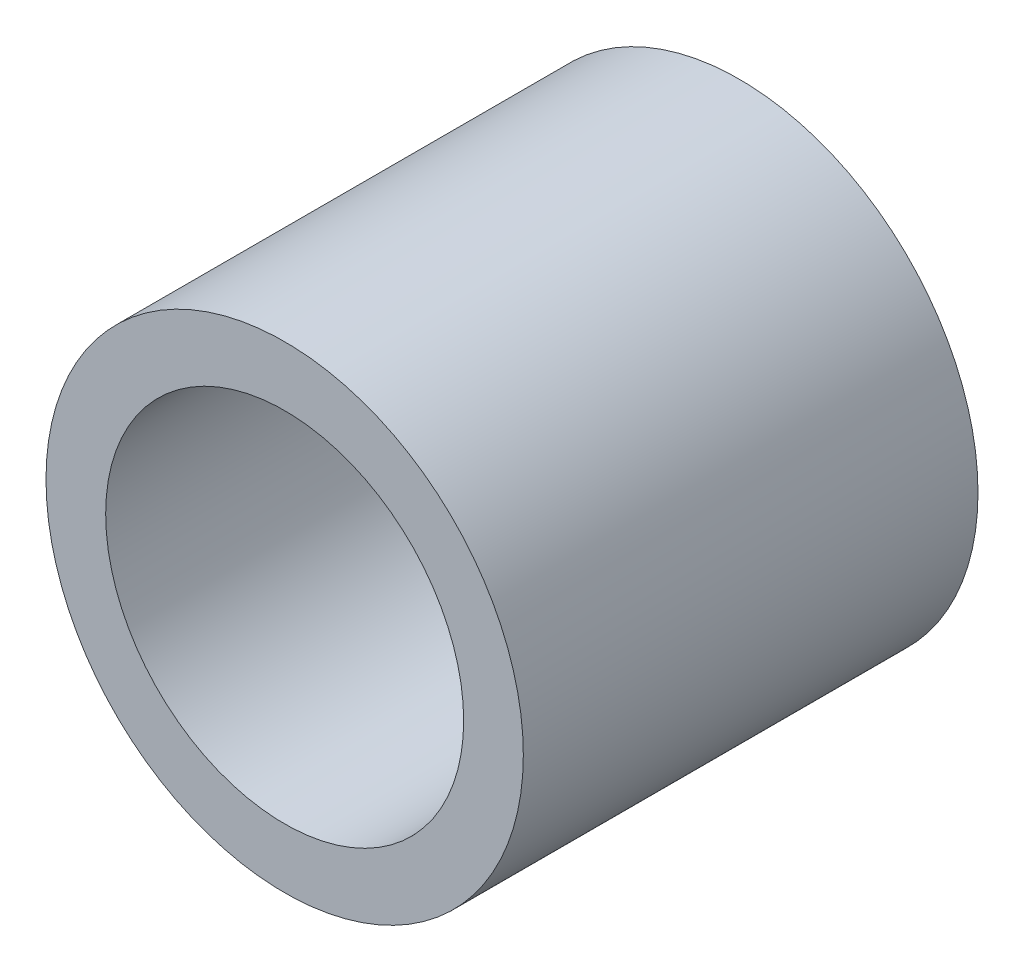
from build123d import *

# Parameters (mm, degrees)
SKETCH1_R      = 2
SKETCH1_R_2    = 1.5
EXTRUDE1_DEPTH = 3.81


with BuildPart() as part:
    # Sketch1 → Extrude1 (new body)
    with BuildSketch(Plane.XY):
        Circle(SKETCH1_R)
        Circle(SKETCH1_R_2, mode=Mode.SUBTRACT)
    extrude(amount=EXTRUDE1_DEPTH)


solid = part.part
